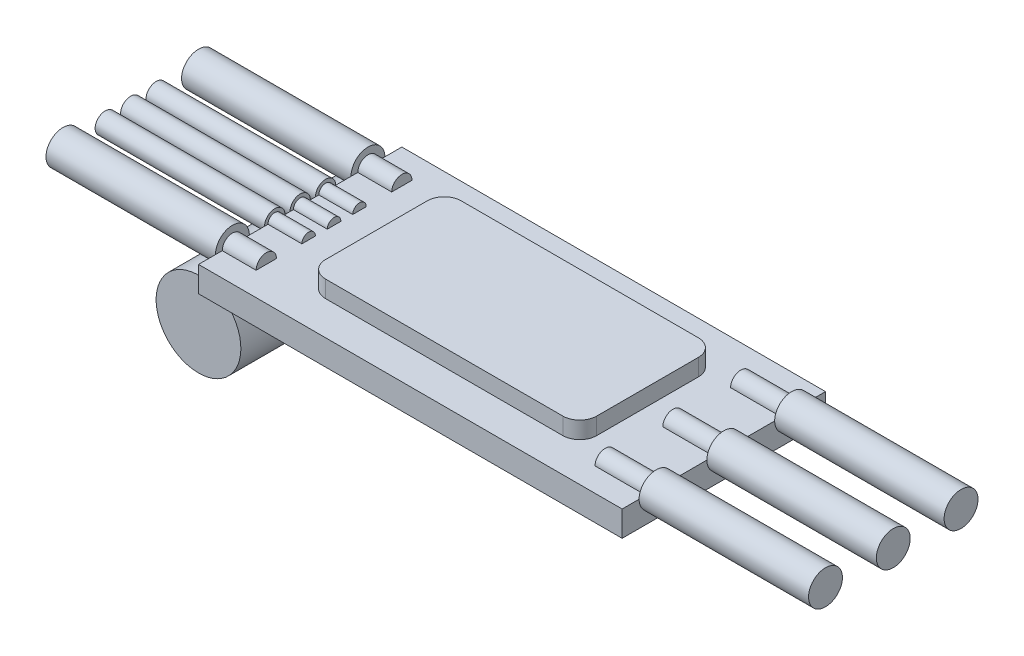
from build123d import *

# Parameters (mm, degrees)
SKETCH1_W            = 25
SKETCH1_H            = 12
BOSS_EXTRUDE1_DEPTH  = 1.5
SKETCH2_R            = 1
BOSS_EXTRUDE2_DEPTH  = 10
SKETCH3_R            = 0.6
BOSS_EXTRUDE3_DEPTH  = 3
SKETCH4_R            = 1
SKETCH4_R_2          = 0.6
BOSS_EXTRUDE4_DEPTH  = 10
SKETCH5_R            = 0.6
SKETCH5_R_2          = 0.4
BOSS_EXTRUDE5_DEPTH  = 2
BOSS_EXTRUDE6_DEPTH  = 1
SKETCH8_R            = 2.5
BOSS_EXTRUDE10_DEPTH = 11
SKETCH9_W            = 6.362334076
SKETCH9_H            = 5.27029166
BOSS_EXTRUDE11_DEPTH = 1
SKETCH10_W           = 1.899204201
SKETCH10_H           = 1.329442941
SKETCH10_W_2         = 1.614323571
SKETCH10_H_2         = 2.374005252
SKETCH10_W_3         = 3.418567563
SKETCH10_H_3         = 0.85464189
SKETCH10_W_4         = 1.139522521
SKETCH10_W_5         = 1.234482731
SKETCH10_H_4         = 1.804243992
SKETCH10_W_6         = 1.351356835
SKETCH10_W_7         = 3.250561037
SKETCH10_H_5         = 1.187002626
BOSS_EXTRUDE12_DEPTH = 0.8


with BuildPart() as part:
    # Sketch1 → Boss-Extrude1 (new body)
    with BuildSketch(Plane(origin=(0, 0, 0), x_dir=(1, 0, 0), z_dir=(0, 1, 0))):
        Rectangle(SKETCH1_W, SKETCH1_H)
    extrude(amount=BOSS_EXTRUDE1_DEPTH)

    # Sketch2 → Boss-Extrude2 (add)
    with BuildSketch(Plane(origin=(12.5, 0, 0), x_dir=(0, 0, -1), z_dir=(1, 0, 0))):
        with Locations((0, 1.5)):
            Circle(SKETCH2_R)
        with Locations((-4, 1.5)):
            Circle(SKETCH2_R)
        with Locations((4, 1.5)):
            Circle(SKETCH2_R)
    extrude(amount=BOSS_EXTRUDE2_DEPTH)

    # Sketch3 → Boss-Extrude3 (add)
    with BuildSketch(Plane(origin=(12.5, 0, 0), x_dir=(0, 0, -1), z_dir=(1, 0, 0))):
        with Locations((-4, 1.5)):
            Circle(SKETCH3_R)
        with Locations((0, 1.5)):
            Circle(SKETCH3_R)
        with Locations((4, 1.5)):
            Circle(SKETCH3_R)
    extrude(amount=-BOSS_EXTRUDE3_DEPTH)

    # Sketch4 → Boss-Extrude4 (add)
    with BuildSketch(Plane.ZY.offset(12.5)):
        with Locations((-4, 1.5)):
            Circle(SKETCH4_R)
        with Locations((4, 1.5)):
            Circle(SKETCH4_R)
        with Locations((0, 1.5)):
            Circle(SKETCH4_R_2)
        with Locations((1.5, 1.5)):
            Circle(SKETCH4_R_2)
        with Locations((-1.5, 1.5)):
            Circle(SKETCH4_R_2)
    extrude(amount=BOSS_EXTRUDE4_DEPTH)

    # Sketch5 → Boss-Extrude5 (add)
    with BuildSketch(Plane(origin=(-12.5, 0, 0), x_dir=(0, 0, -1), z_dir=(1, 0, 0))):
        with Locations((-4, 1.5)):
            Circle(SKETCH5_R)
        with Locations((-1.5, 1.5)):
            Circle(SKETCH5_R_2)
        with Locations((0, 1.5)):
            Circle(SKETCH5_R_2)
        with Locations((1.5, 1.5)):
            Circle(SKETCH5_R_2)
        with Locations((4, 1.5)):
            Circle(SKETCH5_R)
    extrude(amount=BOSS_EXTRUDE5_DEPTH)

    # Sketch6 → Boss-Extrude6 (add)
    with BuildSketch(Plane(origin=(0, 1.5, 0), x_dir=(1, 0, 0), z_dir=(0, 1, 0))):
        with BuildLine():
            Line((-7, -4), (7, -4))
            ThreePointArc((7, -4), (7.707106781, -3.707106781), (8, -3))
            Line((8, -3), (8, 3))
            ThreePointArc((8, 3), (7.707106781, 3.707106781), (7, 4))
            Line((7, 4), (-7, 4))
            ThreePointArc((-7, 4), (-7.707106781, 3.707106781), (-8, 3))
            Line((-8, 3), (-8, -3))
            ThreePointArc((-8, -3), (-7.707106781, -3.707106781), (-7, -4))
        make_face()
    extrude(amount=BOSS_EXTRUDE6_DEPTH)

    # Sketch8 → Boss-Extrude10 (add)
    with BuildSketch(Plane.XY.offset(5.5)):
        with Locations((-13, -2.05)):
            Circle(SKETCH8_R)
    extrude(amount=-BOSS_EXTRUDE10_DEPTH)

    # Sketch9 → Boss-Extrude11 (add)
    with BuildSketch(Plane.XZ):
        Rectangle(SKETCH9_W, SKETCH9_H)
    extrude(amount=BOSS_EXTRUDE11_DEPTH)

    # Sketch10 → Boss-Extrude12 (add)
    with BuildSketch(Plane.XZ):
        with Locations((-8.688859223, 3.347347405)):
            Rectangle(SKETCH10_W, SKETCH10_H)
        with Locations((-7.406896386, -1.780503939)):
            Rectangle(SKETCH10_W_2, SKETCH10_H_2)
        with Locations((1.471883257, -3.917108666)):
            Rectangle(SKETCH10_W_3, SKETCH10_H_3)
        with Locations((4.415649769, -1.780503939)):
            Rectangle(SKETCH10_W_4, SKETCH10_H_2)
        with Locations((5.887533026, 4.012068876)):
            Rectangle(SKETCH10_W_5, SKETCH10_H_4)
        with Locations((7.823260385, 4.012068876)):
            Rectangle(SKETCH10_W_6, SKETCH10_H_4)
        with Locations((7.823260385, 0)):
            Rectangle(SKETCH10_W_7, SKETCH10_H_5)
    extrude(amount=BOSS_EXTRUDE12_DEPTH)


solid = part.part
